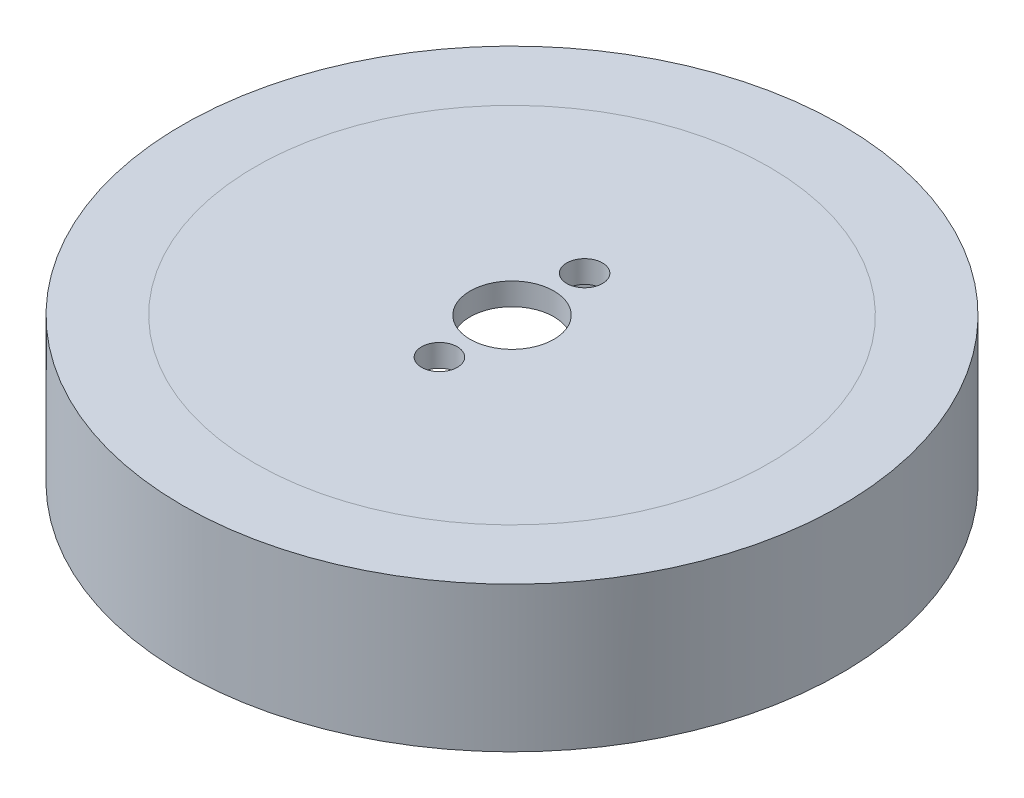
from build123d import *

# Parameters (mm, degrees)
SKETCH_1_R          = 23
SKETCH_1_R_2        = 1.6
SKETCH_1_R_3        = 3.75
EXTRUDE_1_DEPTH     = 13
SKETCH_3_R          = 21
CUT_EXTRUDE_1_DEPTH = 11
SKETCH_4_R          = 29.5
SKETCH_4_R_2        = 23
EXTRUDE_2_DEPTH     = 13


with BuildPart() as part:
    # 草图1 → 凸台-拉伸1 (new body)
    with BuildSketch(Plane(origin=(0, 0, 0), x_dir=(1, 0, 0), z_dir=(0, 1, 0))):
        Circle(SKETCH_1_R)
        with Locations((0, 6.5)):
            Circle(SKETCH_1_R_2, mode=Mode.SUBTRACT)
        with Locations((0, -6.5)):
            Circle(SKETCH_1_R_2, mode=Mode.SUBTRACT)
        Circle(SKETCH_1_R_3, mode=Mode.SUBTRACT)
    extrude(amount=EXTRUDE_1_DEPTH)

    # 草图3 → 切除-拉伸1 (cut)
    with BuildSketch(Plane.XZ):
        Circle(SKETCH_3_R)
    extrude(amount=-CUT_EXTRUDE_1_DEPTH, mode=Mode.SUBTRACT)


with BuildPart() as body_2:
    # 草图4 → 凸台-拉伸2 (new body)
    with BuildSketch(Plane.XZ):
        Circle(SKETCH_4_R)
        Circle(SKETCH_4_R_2, mode=Mode.SUBTRACT)
    extrude(amount=-EXTRUDE_2_DEPTH)


solid = Compound([part.part, body_2.part])
